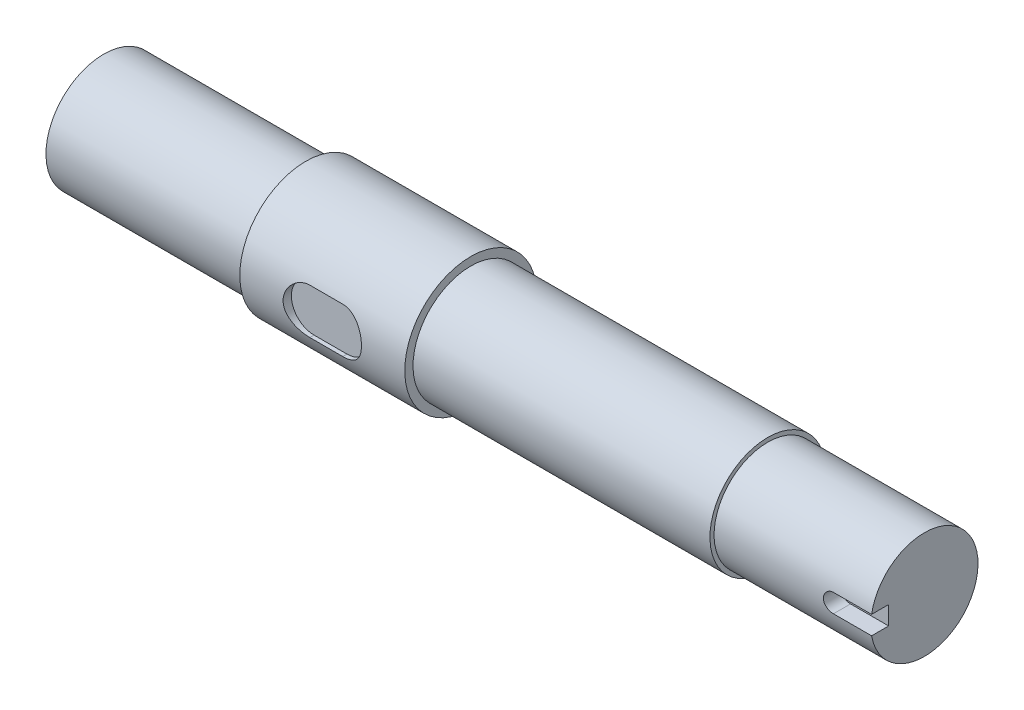
from build123d import *

# Parameters (mm, degrees)
CUT_EXTRUDE1_DEPTH = 6.5
CUT_EXTRUDE2_DEPTH = 3


with BuildPart() as part:
    # Sketch1 → Revolve1 (revolve)
    with BuildSketch(Plane.XY):
        Polygon((0, 0), (0, 21), (73.5, 21), (73.5, 24), (133.5, 24), (133.5, 21), (241.5, 21), (241.5, 19.5), (298.5, 19.5), (298.5, 0), align=None)
    revolve(axis=Axis((298.5, 0, 0), (-1, 0, 0)))

    # Sketch3 → Cut-Extrude1 (cut)
    with BuildSketch(Plane.XY.offset(19.5)):
        with BuildLine():
            Line((312.375, -3.375), (284.625, -3.375))
            ThreePointArc((284.625, -3.375), (281.25, 0), (284.625, 3.375))
            Line((284.625, 3.375), (312.375, 3.375))
            ThreePointArc((312.375, 3.375), (315.75, 0), (312.375, -3.375))
        make_face()
    extrude(amount=-CUT_EXTRUDE1_DEPTH, mode=Mode.SUBTRACT)

    # Sketch4 → Cut-Extrude2 (cut)
    with BuildSketch(Plane.XY.offset(24)):
        with BuildLine():
            Line((97.5, 8.25), (109.5, 8.25))
            ThreePointArc((109.5, 8.25), (117.75, 0), (109.5, -8.25))
            Line((109.5, -8.25), (97.5, -8.25))
            ThreePointArc((97.5, -8.25), (89.25, 0), (97.5, 8.25))
        make_face()
    extrude(amount=-CUT_EXTRUDE2_DEPTH, mode=Mode.SUBTRACT)


solid = part.part
